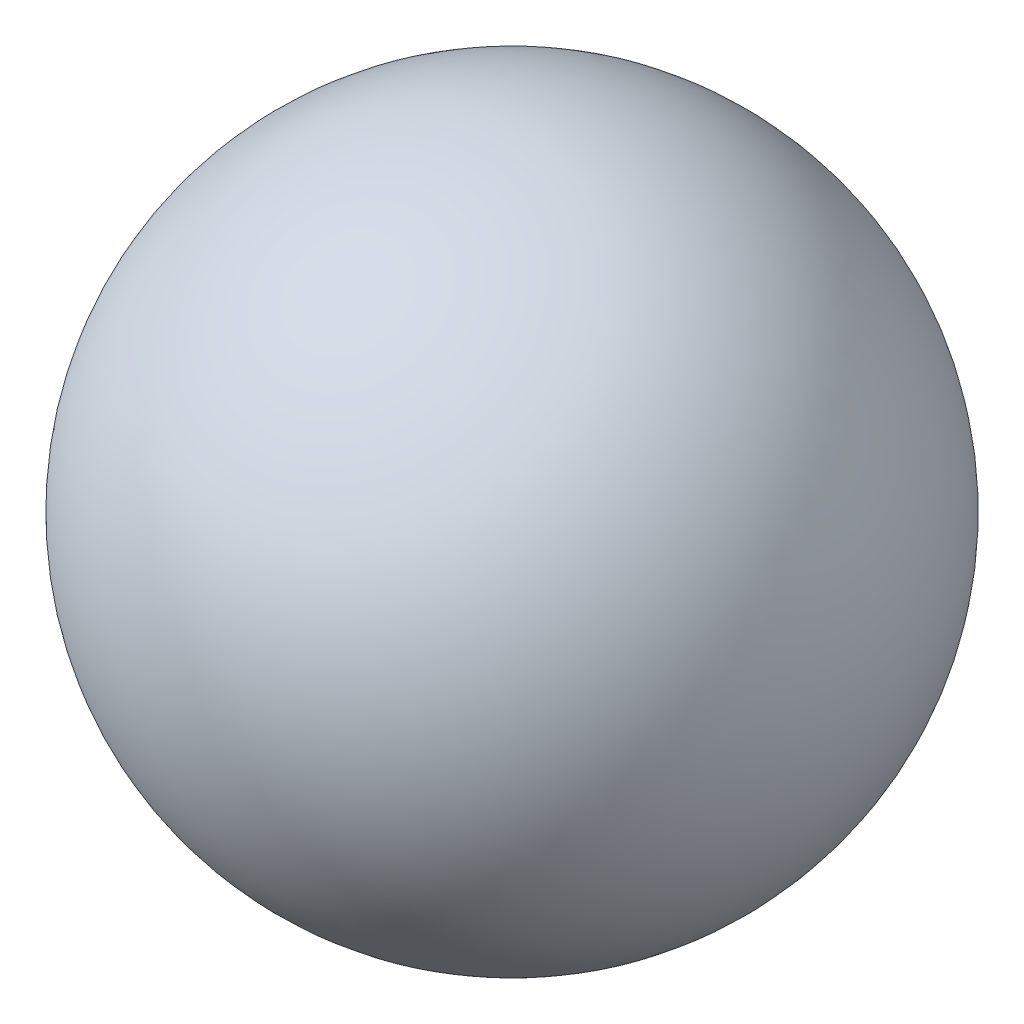
from build123d import *


with BuildPart() as part:
    # Çizim2 → Döndür5 (revolve)
    with BuildSketch(Plane.XY):
        with BuildLine():
            Line((0, 40), (0, -40))
            ThreePointArc((0, -40), (40, 0), (0, 40))
        make_face()
    revolve(axis=Axis((0, 52.489479031, 0), (0, -1, 0)))


solid = part.part
